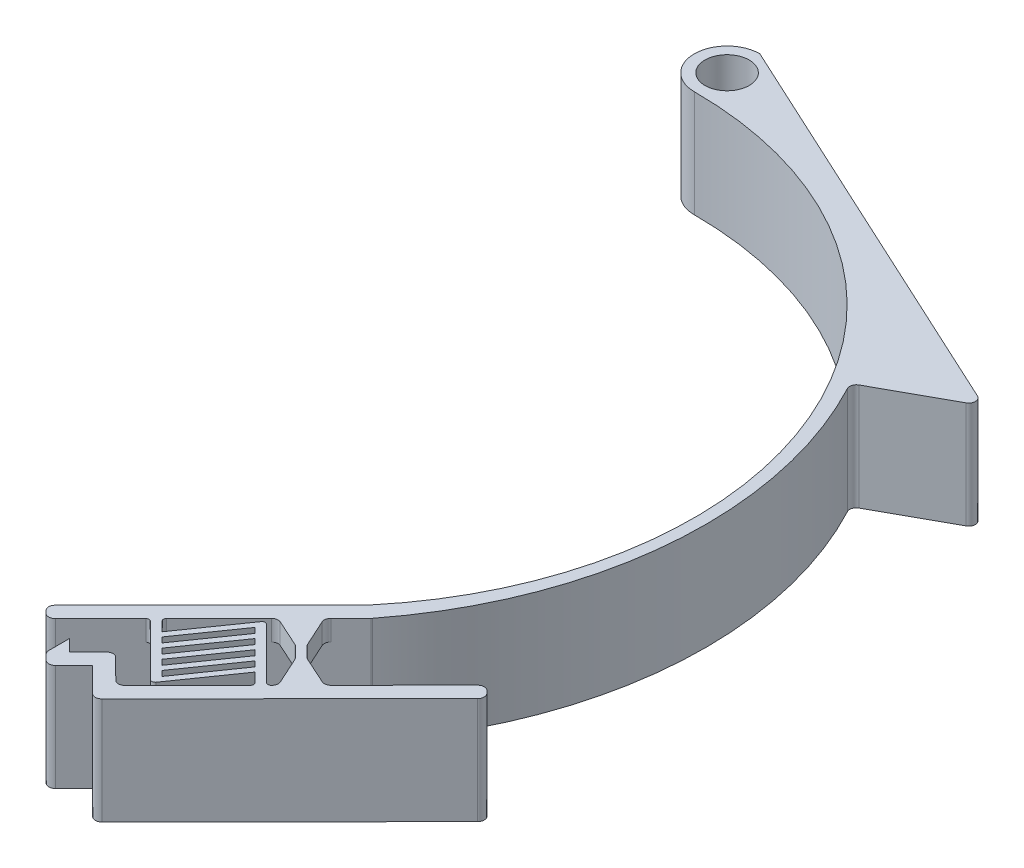
from build123d import *

# Parameters (mm, degrees)
BOSS_EXTRUDE1_DEPTH = 13
SKETCH2_W           = 10
SKETCH2_H           = 8
CUT_EXTRUDE1_DEPTH  = 23
FILLET2_R           = 0.8
FILLET3_R           = 0.4


with BuildPart() as part:
    # Sketch1 → Boss-Extrude1 (new body)
    # profile 1 of 9: a face of its own
    with BuildSketch(Plane(origin=(0, 0, 0), x_dir=(1, 0, 0), z_dir=(0, 1, 0))):
        with BuildLine():
            Line((0, 51.69999999999999), (0, 52.99999999999999))
            ThreePointArc((-9.3e-16, 52.999999999999986), (-4.000000000000001, 48.999999999999986), (0, 44.999999999999986))
            ThreePointArc((0, 44.99999999999999), (40.783850416649216, 19.017821778331506), (34.47199994035405, -28.925442435894198))
            Line((34.47199994035406, -28.9254424358942), (35.888260603401996, -30.337605930077153))
            Line((35.888260603401996, -30.337605930077153), (36.00408882659202, -30.211017655267263))
            ThreePointArc((36.00408882659201, -30.211017655267256), (46.250188794991274, -3.909012128546492), (40.31112943915424, 23.686379393552375))
            ThreePointArc((40.31112943915424, 23.686379393552375), (24.563687739130117, 40.824426362915915), (2.690955139008132, 48.77918233801223))
            ThreePointArc((2.6909551390081288, 48.77918233801222), (-1.985725017136943, 47.17054758019878), (2.055e-14, 51.69999999999999))
        make_face()
    # profile 2 of 9: a face of its own
    with BuildSketch(Plane(origin=(0, 0, 0), x_dir=(1, 0, 0), z_dir=(0, 1, 0))):
        with BuildLine():
            Line((50.82068164403521, 29.47855622552852), (0, 52.99999999999999))
            Line((0, 52.99999999999999), (0, 51.69999999999999))
            ThreePointArc((2.115e-14, 51.69999999999999), (1.909188309203686, 50.90918830920366), (2.7, 48.999999999999986))
            ThreePointArc((2.7, 48.999999999999986), (2.6977378370888774, 48.88949858671026), (2.6909551390081288, 48.77918233801222))
            ThreePointArc((2.690955139008132, 48.77918233801223), (24.563687739130117, 40.824426362915915), (40.31112943915424, 23.686379393552375))
            Line((40.311129439154236, 23.68637939355237), (50.82068164403521, 29.47855622552852))
        make_face()
    # profile 3 of 9: a face of its own
    with BuildSketch(Plane(origin=(0, 0, 0), x_dir=(1, 0, 0), z_dir=(0, 1, 0))):
        Polygon((21.766625661572498, -44.50021256055632), (35.888260603401996, -30.337605930077153), (34.47199994035406, -28.9254424358942), (20.350364998524487, -43.08804906637342), align=None)
    # profile 4 of 9: a face of its own
    with BuildSketch(Plane(origin=(0, 0, 0), x_dir=(1, 0, 0), z_dir=(0, 1, 0))):
        Polygon((34.83733232049475, -37.056649741824835), (33.063933615036056, -33.170127256173025), (30.23960662667018, -36.00264858226883), (34.13125057340328, -37.76478007334881), (35.5475112364512, -39.17694356753177), (37.32090994190985, -43.063466053183646), (40.145236930275736, -40.230944727087746), (36.25359298354269, -38.468813236007804), align=None)
    # profile 5 of 9: a face of its own
    with BuildSketch(Plane(origin=(0, 0, 0), x_dir=(1, 0, 0), z_dir=(0, 1, 0))):
        Polygon((51.446642052604496, -31.729283579935103), (30.26418963986006, -52.973193525654075), (28.84792897681213, -51.56103003147111), (50.03038138955656, -30.317120085752126), align=None)
    # profile 6 of 9: a face of its own
    with BuildSketch(Plane(origin=(0, 0, 0), x_dir=(1, 0, 0), z_dir=(0, 1, 0))):
        Polygon((23.17878915575541, -43.08395189750844), (22.47270740866399, -43.792082229032346), (29.270758591293983, -50.57046700111064), (34.50173196536596, -43.07678265401291), (35.9087464477269, -44.47972671623149), (36.61482819481838, -43.77159638470753), (29.81677701218832, -36.993211612629345), (24.585803638116356, -44.48689595972706), align=None)
        Polygon((32.77765265760353, -41.35769101853769), (28.12789854731734, -48.01874377151343), (27.490581248945773, -47.38327019913109), (32.14033535923197, -40.722217446155355), align=None, mode=Mode.SUBTRACT)
        Polygon((31.596954354536543, -40.1804084146089), (26.947200244250347, -46.84146116758463), (26.309882945878776, -46.20598759520231), (30.959637056164965, -39.54493484222657), align=None, mode=Mode.SUBTRACT)
        Polygon((33.95835096067053, -42.534973622466474), (29.308596850384333, -49.196026375442216), (28.671279552012766, -48.560552803059885), (33.321033662298966, -41.89950005008415), align=None, mode=Mode.SUBTRACT)
        Polygon((30.416256051469542, -39.00312581068011), (25.766501941183353, -45.664178563655845), (25.129184642811783, -45.02870499127351), (29.778938753097975, -38.36765223829777), align=None, mode=Mode.SUBTRACT)
    # profile 7 of 9: a face of its own
    with BuildSketch(Plane(origin=(0, 0, 0), x_dir=(1, 0, 0), z_dir=(0, 1, 0))):
        Polygon((27.435765482629172, -52.977290694519034), (28.84792897681213, -51.56103003147111), (30.26418963986006, -52.973193525654075), (27.439862651494142, -55.805714851749926), (23.899210993874338, -52.27530611629255), (21.074884005508324, -55.10782744238849), (19.658623342460395, -53.69566394820553), (23.895113825009364, -49.446881959061656), align=None)
    # profile 8 of 9: a face of its own
    with BuildSketch(Plane(origin=(0, 0, 0), x_dir=(1, 0, 0), z_dir=(0, 1, 0))):
        Polygon((19.658623342460395, -53.69566394820553), (21.07078683664336, -52.27940328515759), (19.654526173595425, -50.86723979097463), align=None)
    # profile 9 of 9: a face of its own
    with BuildSketch(Plane(origin=(0, 0, 0), x_dir=(1, 0, 0), z_dir=(0, 1, 0))):
        Polygon((20.350364998524487, -43.08804906637342), (14.701711021792637, -48.753091718565145), (16.11797168484057, -50.165255212748114), (21.766625661572498, -44.50021256055632), align=None)
    extrude(amount=BOSS_EXTRUDE1_DEPTH)

    # Sketch2 → Cut-Extrude1 (cut)
    with BuildSketch(Plane(origin=(-10.69214872852209, 0, 10.723170305733387), x_dir=(0.7081303315239577, 0, 0.7060817470914894), z_dir=(-0.7060817470914894, 0, 0.7081303315239577))):
        with Locations((51.834395676587455, 6.499999999999998)):
            Rectangle(SKETCH2_W, SKETCH2_H)
    extrude(amount=-CUT_EXTRUDE1_DEPTH, mode=Mode.SUBTRACT)

    # Fillet2
    fillet2_edges = [part.edges().sort_by_distance(p)[0] for p in [
        (35.5475112364512, 11.75, 39.17694356753177),
        (34.13125057340328, 11.75, 37.76478007334881),
        (30.23960662667018, 11.75, 36.00264858226883),
        (37.32090994190983, 11.75, 43.06346605318363),
        (50.03038138955656, 6.5, 30.317120085752126),
        (51.446642052604496, 6.5, 31.729283579935103),
        (27.439862651494142, 6.5, 55.805714851749926),
        (21.074884005508324, 6.5, 55.10782744238849),
        (19.658623342460395, 6.5, 53.69566394820553),
        (23.895113825009364, 6.5, 49.446881959061656),
        (27.435765482629172, 6.5, 52.977290694519034),
        (16.11797168484057, 6.5, 50.165255212748114),
        (14.701711021792637, 6.5, 48.753091718565145),
        (50.82068164403521, 6.5, -29.47855622552852),
        (40.31112943915424, 6.5, -23.68637939355238),
        (33.063933615036056, 11.75, 33.170127256173025),
        (34.83733232049475, 11.75, 37.056649741824835),
        (36.25359298354269, 11.75, 38.468813236007804),
        (40.14523693027576, 11.75, 40.23094472708776),
        (33.063933615036056, 1.2499999999999993, 33.170127256173025),
        (34.83733232049475, 1.2499999999999993, 37.056649741824835),
        (36.25359298354269, 1.2499999999999993, 38.468813236007804),
        (40.14523693027576, 1.2499999999999993, 40.23094472708776),
        (30.23960662667018, 1.2499999999999993, 36.00264858226883),
        (37.32090994190983, 1.2499999999999993, 43.06346605318363),
    ]]
    fillet(fillet2_edges, radius=FILLET2_R)

    # Fillet3
    fillet3_edges = [part.edges().sort_by_distance(p)[0] for p in [
        (23.17878915575541, 11.75, 43.08395189750844),
        (29.81677701218832, 11.75, 36.993211612629345),
        (36.61482819481838, 11.75, 43.77159638470753),
        (35.9087464477269, 11.75, 44.47972671623149),
        (29.270758591293983, 11.75, 50.57046700111064),
        (22.472707408664043, 11.75, 43.7920822290324),
        (35.9087464477269, 1.2499999999999993, 44.47972671623149),
        (29.270758591293983, 1.2499999999999993, 50.57046700111064),
        (22.472707408664043, 1.2499999999999993, 43.7920822290324),
        (23.17878915575541, 1.2499999999999993, 43.08395189750844),
        (29.81677701218832, 1.2499999999999993, 36.993211612629345),
        (36.61482819481838, 1.2499999999999993, 43.77159638470753),
    ]]
    fillet(fillet3_edges, radius=FILLET3_R)


solid = part.part
